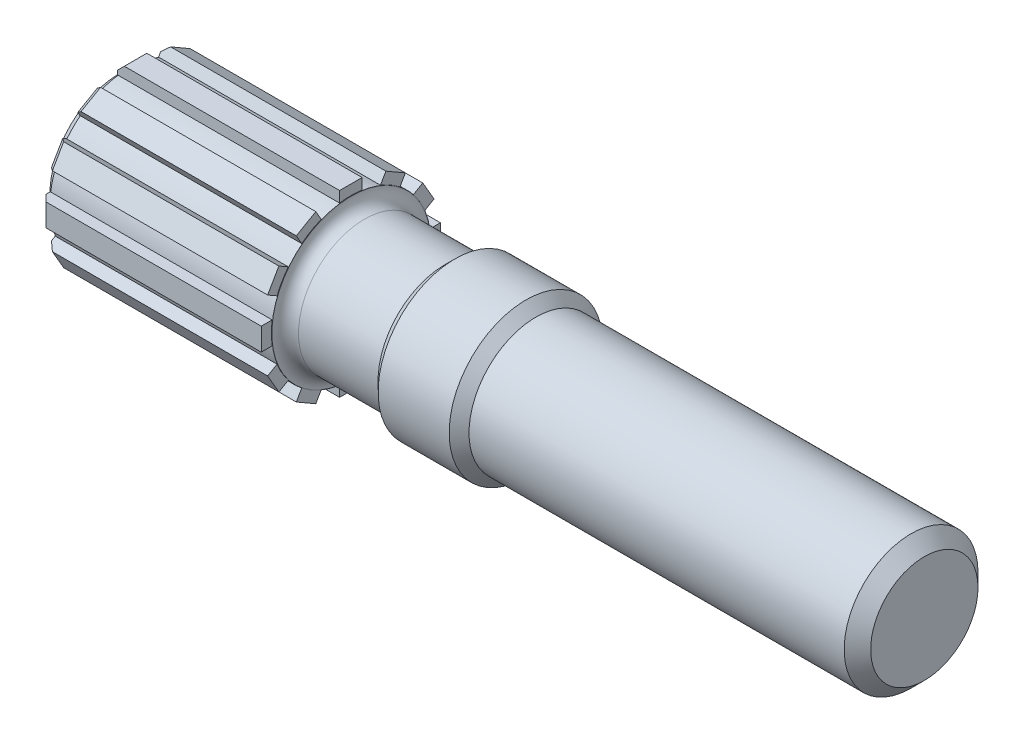
from build123d import *

# Parameters (mm, degrees)
BOSS_EXTRUDE1_START = -1.5
SKETCH2_W           = 3.398401164
SKETCH2_H           = 2.43903778
BOSS_EXTRUDE1_DEPTH = 33.5
CIRPATTERN1_COUNT   = 12
CHAMFER1_SIZE       = 1


with BuildPart() as part:
    # Sketch1 → Revolve1 (revolve)
    with BuildSketch(Plane(origin=(0, 0, 0), x_dir=(1, 0, 0), z_dir=(0, 1, 0))):
        with BuildLine():
            Line((-44.863739249, 0), (76.664890153, 0))
            Line((76.664890153, 0), (76.664890153, 8.102912078))
            Line((76.664890153, 8.102912078), (74.664890153, 10.102912078))
            Line((74.664890153, 10.102912078), (18.02464627, 10.102912078))
            Line((18.02464627, 10.102912078), (16.52464627, 11.60370674))
            Line((16.52464627, 11.60370674), (5.800309153, 11.60370674))
            Line((5.800309153, 11.60370674), (4.300309153, 10.10370674))
            Line((4.300309153, 10.10370674), (4.300309153, 9.962333128))
            Line((4.300309153, 9.962333128), (-7.863739249, 9.962333128))
            ThreePointArc((-7.863739249, 9.962333128), (-9.277952812, 10.548119565), (-9.863739249, 11.962333128))
            Line((-9.863739249, 11.962333128), (-9.863739249, 12))
            Line((-9.863739249, 12), (-43.363739249, 12))
            Line((-43.363739249, 12), (-44.863739249, 10.5))
            Line((-44.863739249, 10.5), (-44.863739249, 0))
        make_face()
    revolve(axis=Axis((77.994791667, 0, 0), (-1, 0, 0)))

    # Sketch2 → Boss-Extrude1 (add)
    with BuildSketch(Plane.ZY.offset(44.921875).offset(BOSS_EXTRUDE1_START)):
        with Locations((0, 12.305085941)):
            Rectangle(SKETCH2_W, SKETCH2_H)
    boss_extrude1 = extrude(amount=-BOSS_EXTRUDE1_DEPTH)

    # CirPattern1: Boss-Extrude1 ×12 about axis
    cirpattern1_axis = Axis((0, 0, 0), (1, 0, 0))
    for i in range(1, CIRPATTERN1_COUNT):
        add(boss_extrude1.rotate(cirpattern1_axis, i * 360 / CIRPATTERN1_COUNT))

    # Chamfer1
    chamfer1_edges = [part.edges().sort_by_distance(p)[0] for p in [
        (-43.421875, -11.71265136, 6.762302416),
        (-43.421875, -13.524604831, 0),
        (-43.421875, -11.71265136, -6.762302416),
        (-43.421875, -6.762302416, -11.71265136),
        (-43.421875, 0, -13.524604831),
        (-43.421875, 6.762302416, -11.71265136),
        (-43.421875, 11.71265136, -6.762302416),
        (-43.421875, 13.524604831, 0),
        (-43.421875, 11.71265136, 6.762302416),
        (-43.421875, 6.762302416, 11.71265136),
        (-43.421875, 0, 13.524604831),
        (-43.421875, -6.762302416, 11.71265136),
    ]]
    chamfer(chamfer1_edges, length=CHAMFER1_SIZE)


solid = part.part
